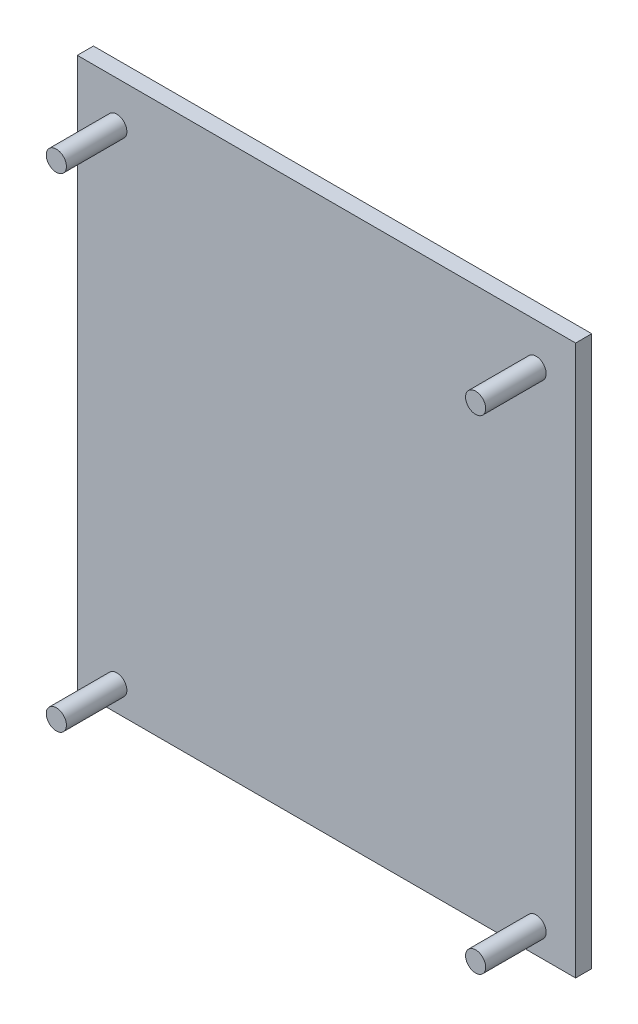
from build123d import *

# Parameters (mm, degrees)
SKETCH1_W           = 78.486
SKETCH1_H           = 86.614
BOSS_EXTRUDE1_DEPTH = 2.54
SKETCH2_R           = 1.5875
BOSS_EXTRUDE2_DEPTH = 9.525


with BuildPart() as part:
    # Sketch1 → Boss-Extrude1 (new body)
    with BuildSketch(Plane.XY):
        with Locations((39.243, 43.307)):
            Rectangle(SKETCH1_W, SKETCH1_H)
    extrude(amount=BOSS_EXTRUDE1_DEPTH)

    # Sketch2 → Boss-Extrude2 (add)
    with BuildSketch(Plane.XY.offset(2.54)):
        with Locations((6.223, 80.1116)):
            Circle(SKETCH2_R)
        with Locations((72.263, 80.1116)):
            Circle(SKETCH2_R)
        with Locations((72.263, 3.9116)):
            Circle(SKETCH2_R)
        with Locations((6.223, 3.9116)):
            Circle(SKETCH2_R)
    extrude(amount=BOSS_EXTRUDE2_DEPTH)


solid = part.part
